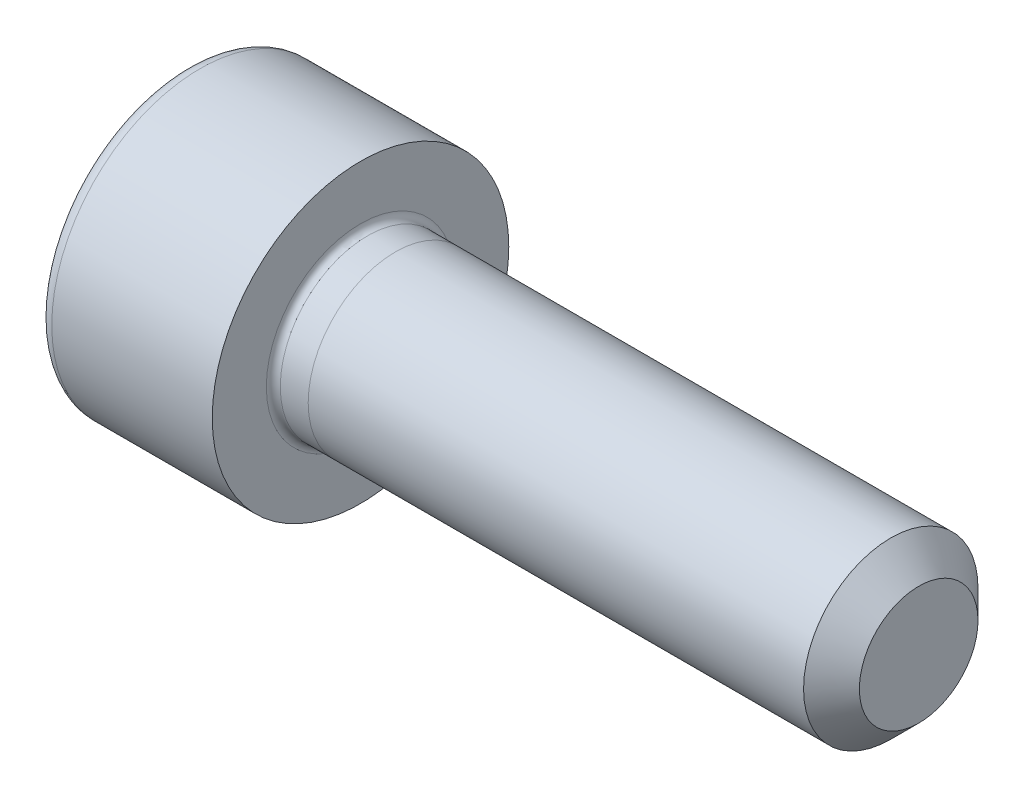
from build123d import *

# Parameters (mm, degrees)
SKETCH_1_R          = 2.5
EXTRUDE_1_DEPTH     = 16
SKETCH_2_R          = 4.25
EXTRUDE_2_DEPTH     = 5
SKETCH_3_R          = 2
CUT_EXTRUDE_1_DEPTH = 3.4
CHAMFER_1_SIZE      = 0.8
FILLET_1_R          = 0.4
FILLET_2_R          = 0.2
CHAMFER_2_SIZE      = 0.4
CHAMFER_2_SIZE2     = 0.230940108
CUT_EXTRUDE_2_DEPTH = 2.8


with BuildPart() as part:
    # Эскиз1 → Вытянуть1 (new body)
    with BuildSketch(Plane(origin=(0, 0, 0), x_dir=(0, 0, -1), z_dir=(1, 0, 0))):
        Circle(SKETCH_1_R)
    extrude(amount=EXTRUDE_1_DEPTH)

    # Эскиз2 → Вытянуть2 (add)
    with BuildSketch(Plane.ZY):
        Circle(SKETCH_2_R)
    extrude(amount=EXTRUDE_2_DEPTH)

    # Эскиз3 → Вырез-Вытянуть1 (cut)
    with BuildSketch(Plane.ZY.offset(5)):
        Circle(SKETCH_3_R)
    extrude(amount=-CUT_EXTRUDE_1_DEPTH, mode=Mode.SUBTRACT)

    # Фаска1
    chamfer_1_edges = [part.edges().sort_by_distance(p)[0] for p in [
        (16, 0, 2.5),
    ]]
    chamfer(chamfer_1_edges, length=CHAMFER_1_SIZE)

    # Скругление1
    fillet_1_edges = [part.edges().sort_by_distance(p)[0] for p in [
        (-5, 0, -4.25),
    ]]
    fillet(fillet_1_edges, radius=FILLET_1_R)

    # Скругление2
    fillet_2_edges = [part.edges().sort_by_distance(p)[0] for p in [
        (0, 0, 2.5),
    ]]
    fillet(fillet_2_edges, radius=FILLET_2_R)

    # Фаска2
    chamfer_2_edges = [part.edges().sort_by_distance(p)[0] for p in [
        (-5, 0, -2),
    ]]
    chamfer_2_side = [part.faces().sort_by_distance(p)[0] for p in [
        (-5, 0, -3.741105556),
    ]]
    chamfer(chamfer_2_edges, length=CHAMFER_2_SIZE, length2=CHAMFER_2_SIZE2, reference=chamfer_2_side[0])

    # Эскиз4 → Вырез-Вытянуть2 (cut)
    with BuildSketch(Plane.ZY.offset(5)):
        Polygon((2.309401077, 0), (1.154700538, 2), (-1.154700538, 2), (-2.309401077, 0), (-1.154700538, -2), (1.154700538, -2), align=None)
    extrude(amount=-CUT_EXTRUDE_2_DEPTH, mode=Mode.SUBTRACT)


solid = part.part
